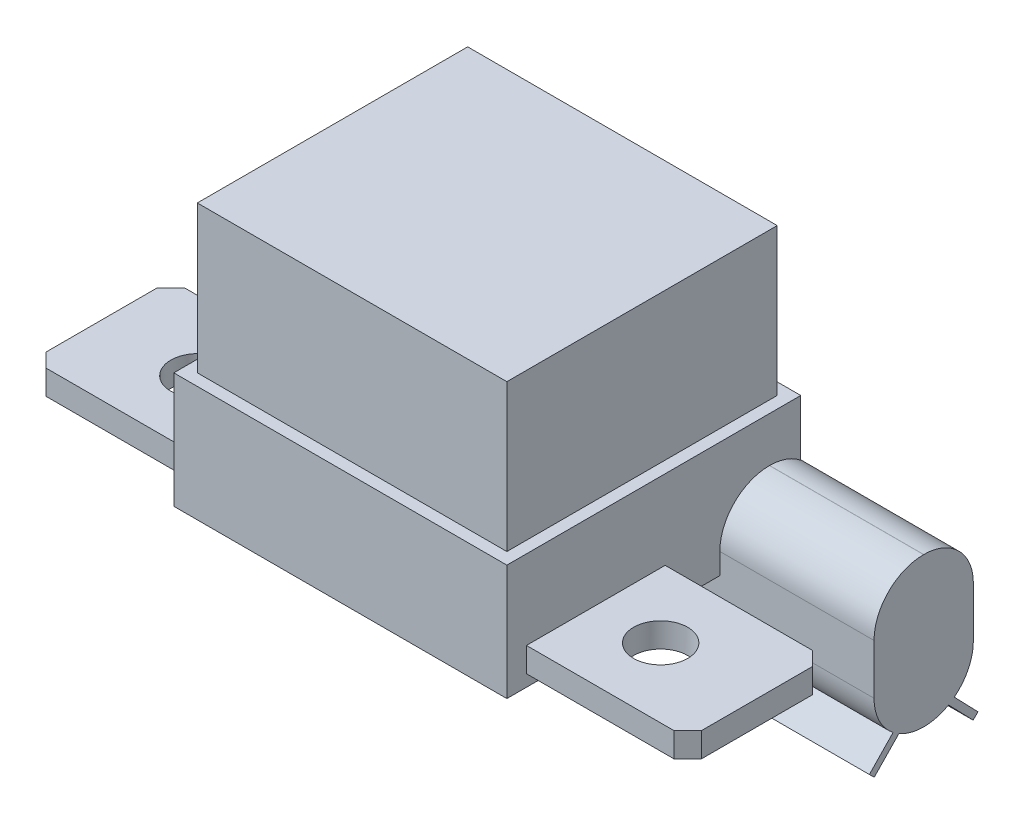
from build123d import *

# Parameters (mm, degrees)
SKETCH1_W                = 43.18
SKETCH1_H                = 38.1
BOSS_EXTRUDE1_DEPTH      = 14.986
SKETCH3_W                = 40.132
SKETCH3_H                = 35.052
BOSS_EXTRUDE2_DEPTH      = 19.0754
SKETCH4_W                = 17.9832
SKETCH4_H                = 3.175
BOSS_EXTRUDE3_DEPTH      = 20.9042
SKETCH6_R                = 3.5052
CUT_EXTRUDE2_DEPTH       = 5.699
CHAMFER1_SIZE            = 1.79578
CHAMFER2_SIZE            = 1.79578
BOSS_EXTRUDE4_DEPTH      = 19.9898
BOSS_EXTRUDE4_DEPTH_BACK = 7.47522
BOSS_EXTRUDE5_DEPTH      = 19.9898


with BuildPart() as part:
    # Sketch1 → Boss-Extrude1 (new body)
    with BuildSketch(Plane(origin=(0, 0, 0), x_dir=(1, 0, 0), z_dir=(0, 1, 0))):
        with Locations((21.59, 19.05)):
            Rectangle(SKETCH1_W, SKETCH1_H)
    extrude(amount=BOSS_EXTRUDE1_DEPTH)

    # Sketch3 → Boss-Extrude2 (add)
    with BuildSketch(Plane(origin=(0, 14.986, 0), x_dir=(1, 0, 0), z_dir=(0, 1, 0))):
        with Locations((21.59, 19.05)):
            Rectangle(SKETCH3_W, SKETCH3_H)
    extrude(amount=BOSS_EXTRUDE2_DEPTH)

    # Sketch4 → Boss-Extrude3 (add)
    with BuildSketch(Plane.ZY):
        with Locations((-11.5316, 3.1115)):
            Rectangle(SKETCH4_W, SKETCH4_H)
    boss_extrude3 = extrude(amount=BOSS_EXTRUDE3_DEPTH)

    # Mirror1: Boss-Extrude3 across plane
    add(boss_extrude3.mirror(Plane(origin=(21.59, 0, 0), x_dir=(0, 0, 1), z_dir=(1, 0, 0))))

    # Sketch6 → Cut-Extrude2 (cut, through all)
    with BuildSketch(Plane(origin=(0, 4.699, 0), x_dir=(1, 0, 0), z_dir=(0, 1, 0))):
        with Locations((-8.4074, 11.5316)):
            Circle(SKETCH6_R)
    cut_extrude2 = extrude(amount=-CUT_EXTRUDE2_DEPTH, mode=Mode.SUBTRACT)

    # Mirror3: Cut-Extrude2 across plane
    add(cut_extrude2.mirror(Plane(origin=(21.59, 0, 0), x_dir=(0, 0, 1), z_dir=(1, 0, 0))), mode=Mode.SUBTRACT)

    # Chamfer1
    chamfer1_edges = [part.edges().sort_by_distance(p)[0] for p in [
        (64.0842, 3.1115, -20.5232),
        (64.0842, 3.1115, -2.54),
    ]]
    chamfer(chamfer1_edges, length=CHAMFER1_SIZE)

    # Chamfer2
    chamfer2_edges = [part.edges().sort_by_distance(p)[0] for p in [
        (-20.9042, 3.1115, -20.5232),
        (-20.9042, 3.1115, -2.54),
    ]]
    chamfer(chamfer2_edges, length=CHAMFER2_SIZE)

    # Sketch7 → Boss-Extrude4 (add, two sides)
    with BuildSketch(Plane(origin=(43.18, 0, 0), x_dir=(0, 0, -1), z_dir=(1, 0, 0))) as boss_extrude4_sk:
        with BuildLine():
            Line((34.0614, 9.144), (34.036, 9.144))
            ThreePointArc((34.036, 9.144), (29.491990403, 7.261809597), (27.6098, 2.7178))
            Line((27.6098, 2.7178), (27.6098, 0))
            Line((27.6098, 0), (38.1, 0))
            Line((38.1, 0), (38.1, 7.716375445))
            ThreePointArc((38.1, 7.716375445), (36.203151726, 8.776590802), (34.0614, 9.144))
        make_face()
        with BuildLine():
            ThreePointArc((40.4876, 2.7178), (39.860059231, 5.487564893), (38.1, 7.716375445))
            Line((38.1, 7.716375445), (38.1, 0))
            Line((38.1, 0), (27.6098, 0))
            Line((27.6098, 0), (27.6098, -3.7719))
            ThreePointArc((27.6098, -3.7719), (28.261339144, -6.594290394), (30.084100746, -8.845496946))
            Line((30.084100746, -8.845496946), (34.0487, -4.740034236))
            Line((34.0487, -4.740034236), (38.016880079, -8.849204998))
            ThreePointArc((38.016880079, -8.849204998), (39.836984495, -6.602164583), (40.4876, -3.7846))
            Line((40.4876, -3.7846), (40.4876, 2.7178))
        make_face()
        with BuildLine():
            Line((34.0487, -6.0198), (30.832652906, -9.350114257))
            ThreePointArc((30.832652906, -9.350114257), (32.384087518, -9.991907918), (34.0487, -10.2108))
            Line((34.0487, -10.2108), (34.0487, -6.0198))
        make_face()
        with BuildLine():
            ThreePointArc((34.0614, -10.2108), (35.721039602, -9.992791591), (37.268072877, -9.353558206))
            Line((37.268072877, -9.353558206), (34.0487, -6.0198))
            Line((34.0487, -6.0198), (34.0487, -10.2108))
            Line((34.0487, -10.2108), (34.0614, -10.2108))
        make_face()
        with BuildLine():
            Line((34.0487, -4.740034236), (30.084100746, -8.845496946))
            ThreePointArc((30.084100746, -8.845496946), (30.449522295, -9.110940462), (30.832652906, -9.350114257))
            Line((30.832652906, -9.350114257), (34.0487, -6.0198))
            Line((34.0487, -6.0198), (37.268072877, -9.353558206))
            ThreePointArc((37.268072877, -9.353558206), (37.651344537, -9.114547904), (38.016880079, -8.849204998))
            Line((38.016880079, -8.849204998), (34.0487, -4.740034236))
        make_face()
    extrude(amount=BOSS_EXTRUDE4_DEPTH)
    extrude(boss_extrude4_sk.sketch, amount=-BOSS_EXTRUDE4_DEPTH_BACK)

    # Sketch7_3 → Boss-Extrude5 (add)
    with BuildSketch(Plane(origin=(43.18, 0, 0), x_dir=(0, 0, -1), z_dir=(1, 0, 0))):
        Polygon((34.0487, -4.740034236), (27.007269754, -12.031648709), (27.646762836, -12.6492), (34.0487, -6.0198), (40.450637164, -12.6492), (41.090130246, -12.031648709), align=None)
    extrude(amount=BOSS_EXTRUDE5_DEPTH)


solid = part.part
